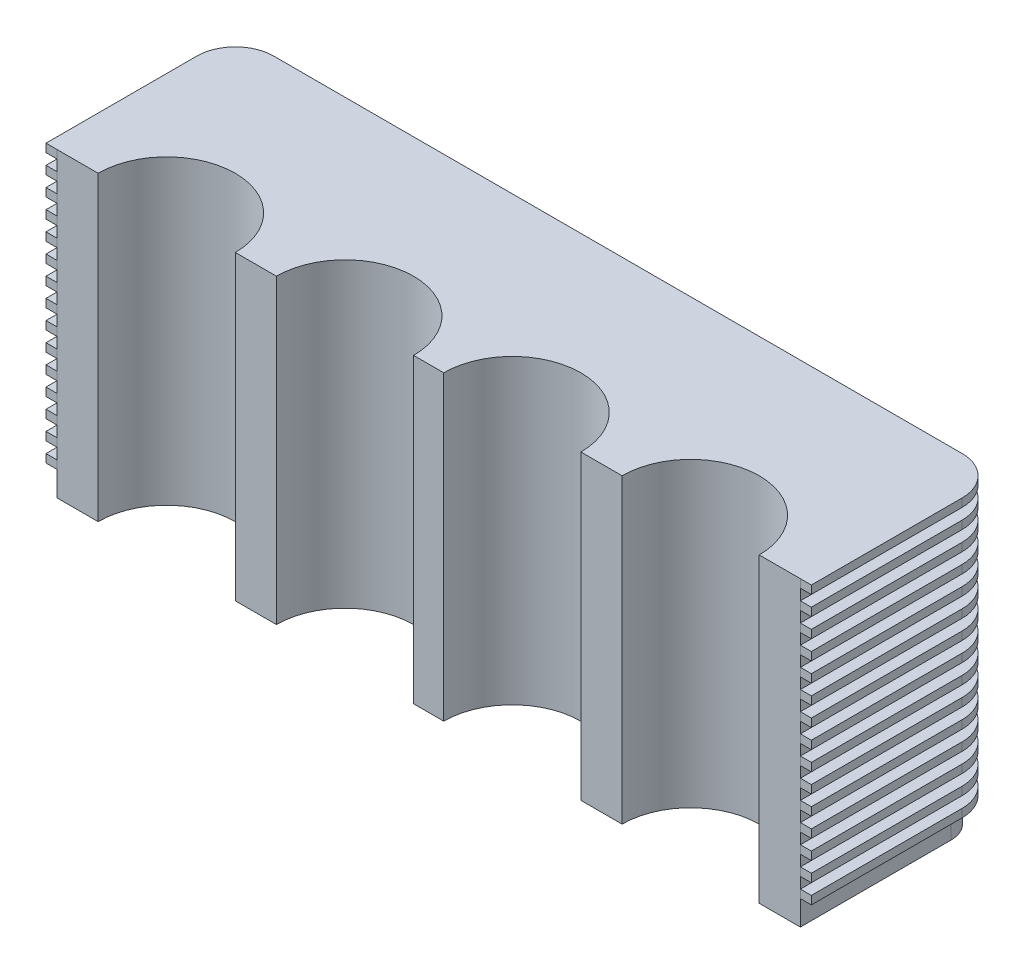
from build123d import *

# Parameters (mm, degrees)
BOSS_EXTRUDE1_DEPTH = 2794
BOSS_EXTRUDE4_DEPTH = 76.2
LPATTERN1_COUNT     = 15
LPATTERN1_PITCH     = 177.8


with BuildPart() as part:
    # Sketch1 → Boss-Extrude1 (new body)
    with BuildSketch(Plane(origin=(0, 0, 0), x_dir=(1, 0, 0), z_dir=(0, 1, 0))):
        with BuildLine():
            Line((0, 0), (381, 0))
            ThreePointArc((381, 0), (1016, 635), (1651, 0))
            Line((1651, 0), (2032, 0))
            ThreePointArc((2032, 0), (2667, 635), (3302, 0))
            Line((3302, 0), (3581.4, 0))
            ThreePointArc((3581.4, 0), (4216.4, 635), (4851.4, 0))
            Line((4851.4, 0), (5232.4, 0))
            ThreePointArc((5232.4, 0), (5867.4, 635), (6502.4, 0))
            Line((6502.4, 0), (6883.4, 0))
            Line((6883.4, 0), (6883.4, 1397))
            ThreePointArc((6883.4, 1397), (6809.005122421, 1576.605122421), (6629.4, 1651))
            Line((6629.4, 1651), (254, 1651))
            ThreePointArc((254, 1651), (74.394877579, 1576.605122421), (0, 1397))
            Line((0, 1397), (0, 0))
        make_face()
    extrude(amount=BOSS_EXTRUDE1_DEPTH)

    # Sketch5 → Boss-Extrude4 (add)
    with BuildSketch(Plane(origin=(0, 2794, 0), x_dir=(1, 0, 0), z_dir=(0, 1, 0))):
        with BuildLine():
            Line((6985, 0.124642003), (6985, 1397))
            ThreePointArc((6985, 1397), (6880.84717139, 1648.44717139), (6629.4, 1752.6))
            Line((6629.4, 1752.6), (254, 1752.6))
            ThreePointArc((254, 1752.6), (2.55282861, 1648.44717139), (-101.6, 1397))
            Line((-101.6, 1397), (-101.6, 0.046050428))
            Line((-101.6, 0.046050428), (0, 0.046050428))
            Line((0, 0.046050428), (0, 1397))
            ThreePointArc((0, 1397), (74.394877579, 1576.605122421), (254, 1651))
            Line((254, 1651), (6629.4, 1651))
            ThreePointArc((6629.4, 1651), (6809.005122421, 1576.605122421), (6883.4, 1397))
            Line((6883.4, 1397), (6883.4, 0.124642003))
            Line((6883.4, 0.124642003), (6985, 0.124642003))
        make_face()
    boss_extrude4 = extrude(amount=-BOSS_EXTRUDE4_DEPTH)

    # LPattern1: Boss-Extrude4 ×15
    with Locations(*[(0, -i * LPATTERN1_PITCH, 0) for i in range(1, LPATTERN1_COUNT)]):
        add(boss_extrude4)


solid = part.part
